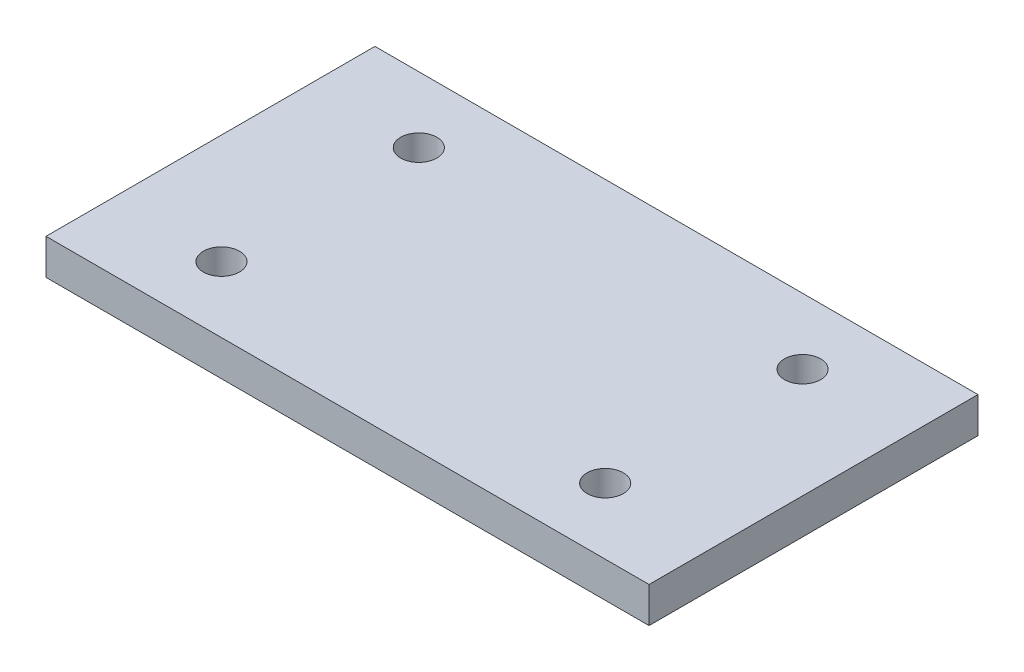
from build123d import *

# Parameters (mm, degrees)
SKETCH1_W           = 55
SKETCH1_H           = 30
SKETCH1_R           = 1.65
BOSS_EXTRUDE1_DEPTH = 3.25


with BuildPart() as part:
    # Sketch1 → Boss-Extrude1 (new body)
    with BuildSketch(Plane(origin=(0, 0, 0), x_dir=(1, 0, 0), z_dir=(0, 1, 0))):
        Rectangle(SKETCH1_W, SKETCH1_H)
        with Locations((-17.5, 9)):
            Circle(SKETCH1_R, mode=Mode.SUBTRACT)
        with Locations((17.5, 9)):
            Circle(SKETCH1_R, mode=Mode.SUBTRACT)
        with Locations((17.5, -9)):
            Circle(SKETCH1_R, mode=Mode.SUBTRACT)
        with Locations((-17.5, -9)):
            Circle(SKETCH1_R, mode=Mode.SUBTRACT)
    extrude(amount=BOSS_EXTRUDE1_DEPTH)


solid = part.part
